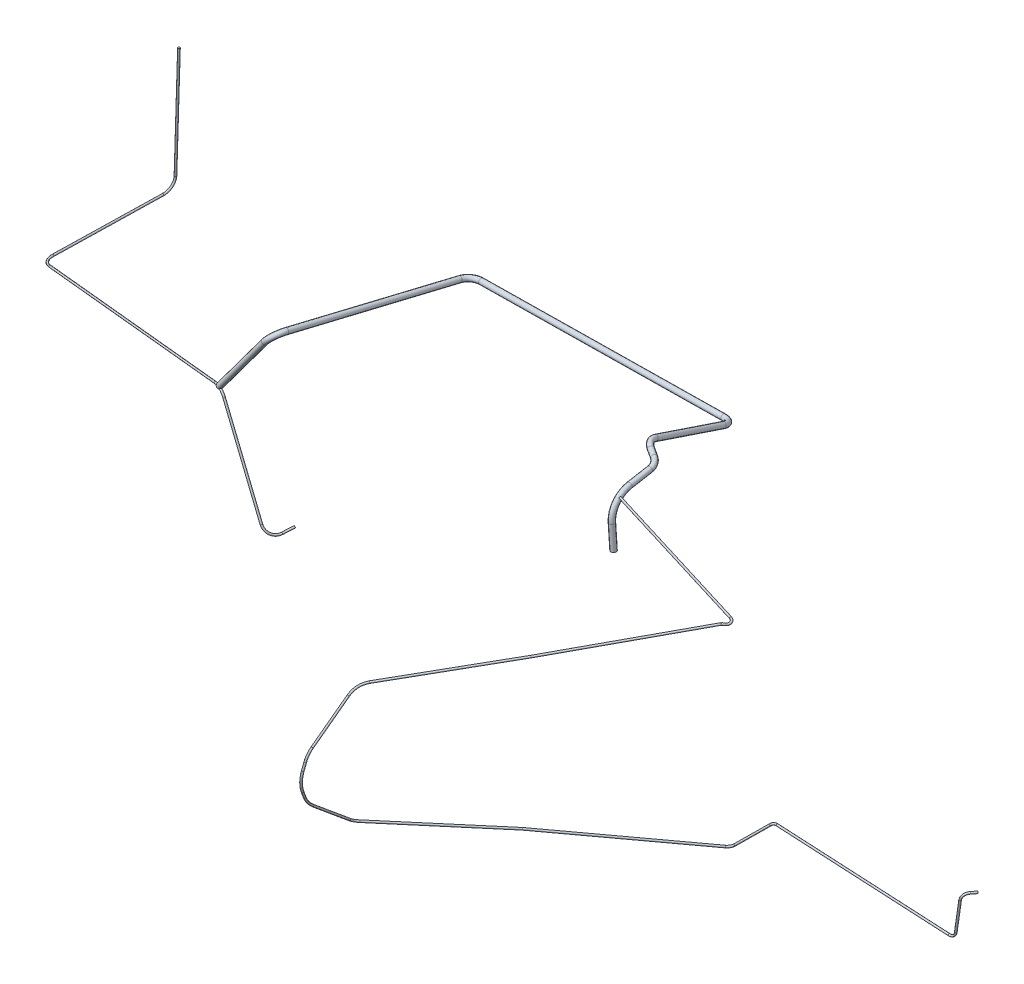
from build123d import *

# Parameters (mm, degrees)
WYCI_GNI_CIE_PO_CIE_CE1_PROFILE_R = 2.5
WYCI_GNI_CIE_PO_CIE_CE6_PROFILE_R = 7
WYCI_GNI_CIE_PO_CIE_CE8_PROFILE_R = 2.5
WYCI_GNI_CIE_PO_CIE_CE9_PROFILE_R = 2.5
SWEEP2_PROFILE_R                  = 2.5
SWEEP3_PROFILE_R                  = 2.5


with BuildPart() as part:
    # Wyciągnięcie po ścieżce1: sweep along a curve in space
    with BuildLine() as wyci_gni_cie_po_cie_ce1_path:
        Line((118.633362793, -241.815154907, 530.812750571), (126.147671788, -236.192852417, 505.191443979))
        ThreePointArc((92.707429588, -219.047070877, 559.880005502), (107.076745313, -237.755491592, 552.337852932), (118.633362793, -241.815154907, 530.812750571))
        Line((92.707429588, -219.047070877, 559.880005502), (-28.161608304, -0.647400384, 537.444474429))
        ThreePointArc((-28.161608304, -0.647400384, 537.444474429), (-41.103371704, 11.730265967, 534.649840636), (-58.539261, 14.232118297, 530.379437656))
        Line((-58.539261, 14.232118297, 530.379437656), (-646.253772705, -88.796108132, 379.756814279))
        ThreePointArc((-668.643523215, -91.649335936, 348.048818997), (-663.164062022, -91.456239693, 368.049600458), (-646.253772705, -88.796108132, 379.756814279))
        Line((-668.643523215, -91.649335936, 348.048818997), (-647.213158325, -76.580026216, 79.429552716))
        ThreePointArc((-642.269540707, -45.239202479, 51.440262378), (-644.784000377, -66.71983682, 58.921415933), (-647.213158325, -76.580026216, 79.429552716))
        Line((-642.269540707, -45.239202479, 51.440262378), (-614.884465929, 270.401405982, 69.576213478))
    # Wyciągnięcie po ścieżce1 profile (on start of the path) → Wyciągnięcie po ścieżce1 (sweep)
    with BuildSketch(Plane(origin=(-614.884465929, 270.401405982, 69.576213478), x_dir=(-0.99625744, 0.086435597, 0), z_dir=(-0.086294332, -0.994629217, -0.057149005))):
        Circle(WYCI_GNI_CIE_PO_CIE_CE1_PROFILE_R)
    sweep(path=wyci_gni_cie_po_cie_ce1_path.line)

    # Wyciągnięcie po ścieżce6: sweep along a curve in space
    with BuildLine() as wyci_gni_cie_po_cie_ce6_path:
        Line((989.802653571, 219.181635577, 531.836899377), (993.064043563, 156.084087205, 530.763334278))
        ThreePointArc((987.61287575, 279.152730354, 482.843536147), (988.048327536, 258.113483469, 518.320551031), (989.802653571, 219.181635577, 531.836899377))
        Line((987.61287575, 279.152730354, 482.843536147), (988.068522471, 289.078741938, 429.773053489))
        ThreePointArc((973.366025514, 297.40511407, 404.574770175), (984.190776741, 292.810841333, 415.004773921), (988.068522471, 289.078741938, 429.773053489))
        Line((973.366025514, 297.40511407, 404.574770175), (955.790663008, 303.433572972, 395.206814518))
        ThreePointArc((938.083293219, 303.069069636, 365.136826426), (942.781396961, 306.120694225, 382.584143215), (955.790663008, 303.433572972, 395.206814518))
        Line((938.083293219, 303.069069636, 365.136826426), (941.615853783, 246.452590165, 189.47229253))
        ThreePointArc((941.615853783, 246.452590165, 189.47229253), (933.653082604, 239.703301847, 169.643408365), (913.411904058, 235.972054606, 160.782497017))
        Line((913.411904058, 235.972054606, 160.782497017), (245.162496633, 197.897836106, 131.61397153))
        ThreePointArc((245.162496633, 197.897836106, 131.61397153), (224.642528635, 197.779810979, 138.455443037), (213.999265226, 199.78031177, 157.179964113))
        Line((213.999265226, 199.78031177, 157.179964113), (154.871039271, 250.888194506, 555.594492718))
        ThreePointArc((154.871039271, 250.888194506, 555.594492718), (144.304125556, 245.549430557, 578.327489963), (127.066670994, 227.595728322, 584.450068343))
        Line((127.066670994, 227.595728322, 584.450068343), (-45.712580672, 13.355864241, 531.010270974))
    # Wyciągnięcie po ścieżce6 profile (on start of the path) → Wyciągnięcie po ścieżce6 (sweep)
    with BuildSketch(Plane(origin=(-45.712580672, 13.355864241, 531.010270974), x_dir=(0.778403864, -0.627763828, 0), z_dir=(0.616254952, 0.764133285, 0.190604714))):
        Circle(WYCI_GNI_CIE_PO_CIE_CE6_PROFILE_R)
    sweep(path=wyci_gni_cie_po_cie_ce6_path.line)

    # Wyciągnięcie po ścieżce8: sweep along a curve in space
    with BuildLine() as wyci_gni_cie_po_cie_ce8_path:
        Line((1297.137751297, 181.242441222, 546.205552947), (993.362097427, 268.815005553, 513.804451426))
    # Wyciągnięcie po ścieżce8 profile (on start of the path) → Wyciągnięcie po ścieżce8 (sweep)
    with BuildSketch(Plane(origin=(1297.137751297, 181.242441222, 546.205552947), x_dir=(-0.276999959, -0.96086993, 0), z_dir=(-0.955862989, 0.275556556, -0.101953574))):
        Circle(WYCI_GNI_CIE_PO_CIE_CE8_PROFILE_R)
    sweep(path=wyci_gni_cie_po_cie_ce8_path.line)



with BuildPart() as body_2:
    # Wyciągnięcie po ścieżce9: sweep along a curve in space
    with BuildLine() as wyci_gni_cie_po_cie_ce9_path:
        Line((1317.999727692, 171.22279664, 571.729587249), (1089.641287715, 119.143321493, 845.116037461))
        Line((1089.641287715, 119.143321493, 845.116037461), (892.008674547, 75.996145536, 1072.976902575))
        ThreePointArc((873.044838559, 54.6235468, 1110.370426706), (879.120421198, 68.694521779, 1091.880709279), (892.008674547, 75.996145536, 1072.976902575))
        Line((873.044838559, 54.6235468, 1110.370426706), (862.085379682, -27.368306552, 1194.737643895))
        ThreePointArc((859.412111454, -54.130868591, 1210.613656322), (860.668419087, -39.689476444, 1204.449178299), (862.085379682, -27.368306552, 1194.737643895))
        Line((859.412111454, -54.130868591, 1210.613656322), (858.056386199, -72.089120782, 1215.614960934))
        ThreePointArc((854.048295932, -123.887279334, 1212.4708885), (856.056155355, -98.252116591, 1218.386050613), (858.056386199, -72.089120782, 1215.614960934))
        Line((854.048295932, -123.887279334, 1212.4708885), (852.748907826, -140.263582358, 1205.684199663))
        ThreePointArc((851.414620087, -171.595718136, 1182.539405935), (851.687004368, -157.331340382, 1196.03209075), (852.748907826, -140.263582358, 1205.684199663))
        Line((851.414620087, -171.595718136, 1182.539405935), (852.245349011, -250.691771681, 1087.071062811))
        ThreePointArc((859.920809001, -260.558010236, 1067.527515727), (854.282287377, -257.107969916, 1077.340761101), (852.245349011, -250.691771681, 1087.071062811))
        Line((859.920809001, -260.558010236, 1067.527515727), (1046.543268041, -305.839159258, 825.172071597))
    # Wyciągnięcie po ścieżce9 profile (on start of the path) → Wyciągnięcie po ścieżce9 (sweep)
    with BuildSketch(Plane(origin=(1317.999727692, 171.22279664, 571.729587249), x_dir=(0.767480191, 0, 0.641072661), z_dir=(-0.634329, -0.144665209, 0.759406806))):
        Circle(WYCI_GNI_CIE_PO_CIE_CE9_PROFILE_R)
    sweep(path=wyci_gni_cie_po_cie_ce9_path.line, transition=Transition.RIGHT)


with BuildPart() as part_1:
    add(part.part)

    add(body_2.part)  # Sweep2 merges body 2
    # Sweep2: sweep along a curve in space
    with BuildLine() as sweep2_path:
        Line((1297.137751297, 181.242441222, 546.205552947), (1319.452616488, 174.809503155, 548.585685138))
        ThreePointArc((1324.520796773, 170.549422769, 565.407210668), (1327.278650461, 171.573216324, 555.121872084), (1319.452616488, 174.809503155, 548.585685138))
        Line((1324.520796773, 170.549422769, 565.407210668), (1317.999727692, 171.22279664, 571.729587249))
    # Sweep2 profile (on start of the path) → Sweep2 (sweep)
    with BuildSketch(Plane(origin=(1297.137751297, 181.242441222, 546.205552947), x_dir=(0.276999959, 0.96086993, 0), z_dir=(0.955862989, -0.275556556, 0.101953574))):
        Circle(SWEEP2_PROFILE_R)
    sweep(path=sweep2_path.line)

    # Sweep3: sweep along a curve in space
    with BuildLine() as sweep3_path:
        Line((1046.543268041, -305.839159258, 825.172071597), (1289.703385484, -370.858695473, 533.191299189))
        ThreePointArc((1289.703385484, -370.858695473, 533.191299189), (1296.779336368, -370.253934208, 526.242644325), (1304.119348156, -365.34233467, 521.690827275))
        Line((1304.119348156, -365.34233467, 521.690827275), (1370.211175978, -300.331135553, 493.591379303))
        ThreePointArc((1385.146618358, -294.284366384, 491.536570005), (1377.008468058, -295.903400043, 491.823580173), (1370.211175978, -300.331135553, 493.591379303))
        Line((1385.146618358, -294.284366384, 491.536570005), (1867.712084458, -289.809715415, 519.994935714))
        ThreePointArc((1867.712084458, -289.809715415, 519.994935714), (1880.313508614, -285.165753527, 520.921707797), (1887.100580814, -273.57250102, 521.789651652))
        Line((1887.100580814, -273.57250102, 521.789651652), (1902.777520787, -190.305610567, 526.08571971))
        ThreePointArc((1917.648897549, -172.282722205, 513.940189375), (1908.408123862, -177.790862939, 523.001341402), (1902.777520787, -190.305610567, 526.08571971))
        Line((1917.648897549, -172.282722205, 513.940189375), (1927.049922725, -171.593042032, 503.414453632))
    # Sweep3 profile (on start of the path) → Sweep3 (sweep)
    with BuildSketch(Plane(origin=(1046.543268041, -305.839159258, 825.172071597), x_dir=(-0.768424697, 0, -0.63994022), z_dir=(0.630772115, -0.168664626, -0.757415859))):
        Circle(SWEEP3_PROFILE_R)
    sweep(path=sweep3_path.line)


solid = part_1.part
